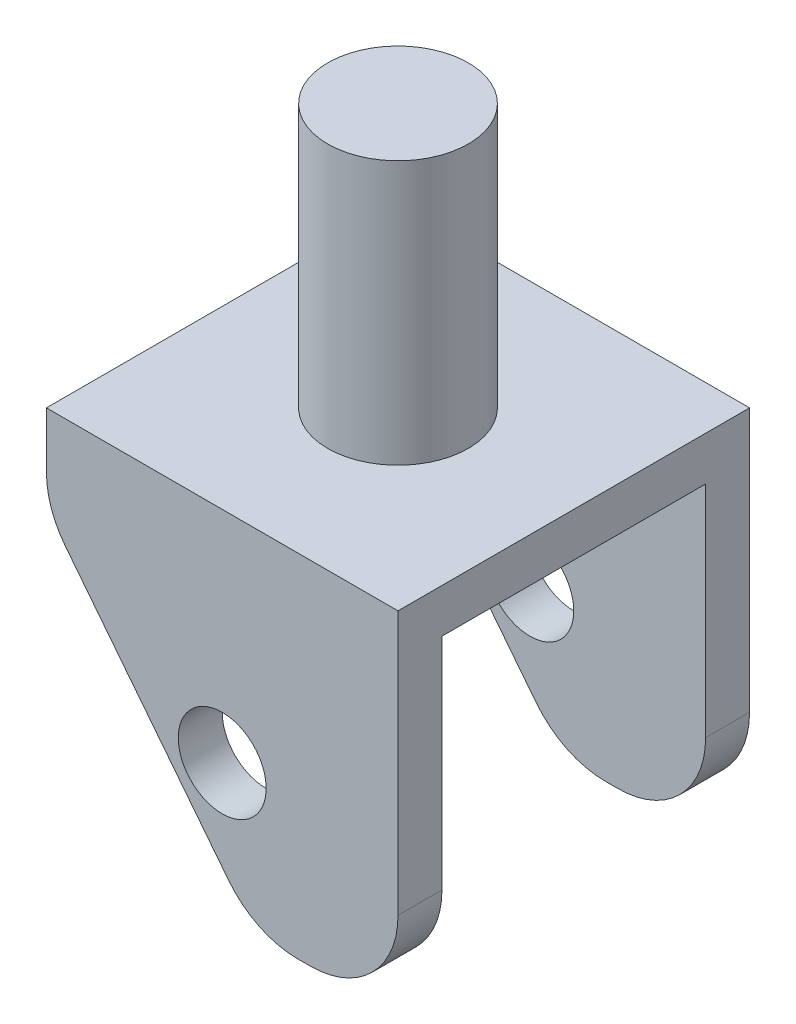
from build123d import *

# Parameters (mm, degrees)
DODANIE_WYCI_GNI_CIE1_DEPTH = 40
SZKIC2_W                    = 30
SZKIC2_H                    = 35
WYTNIJ_WYCI_GNI_CIE1_DEPTH  = 40
SZKIC3_R                    = 5
WYTNIJ_WYCI_GNI_CIE2_DEPTH  = 40
ZAOKR_GLENIE1_R             = 10
SZKIC4_R                    = 8
DODANIE_WYCI_GNI_CIE2_DEPTH = 30


with BuildPart() as part:
    # Szkic1 → Dodanie-wyciągnięcie1 (new body)
    with BuildSketch(Plane.XY):
        Polygon((-8.990228013, 22.917176047), (31.009771987, 22.917176047), (31.009771987, -17.082823953), (14.732595321, -17.082823953), (-8.990228013, 13.105888901), align=None)
    extrude(amount=DODANIE_WYCI_GNI_CIE1_DEPTH)

    # Szkic2 → Wytnij-wyciągnięcie1 (cut)
    with BuildSketch(Plane(origin=(31.009771987, 0, 0), x_dir=(0, 0, -1), z_dir=(1, 0, 0))):
        with Locations((-20, 0.417176047)):
            Rectangle(SZKIC2_W, SZKIC2_H)
    extrude(amount=-WYTNIJ_WYCI_GNI_CIE1_DEPTH, mode=Mode.SUBTRACT)

    # Szkic3 → Wytnij-wyciągnięcie2 (cut)
    with BuildSketch(Plane(origin=(0, 0, 0), x_dir=(-1, 0, 0), z_dir=(0, 0, -1))):
        with Locations((-11.009771987, -2.082823953)):
            Circle(SZKIC3_R)
    extrude(amount=-WYTNIJ_WYCI_GNI_CIE2_DEPTH, mode=Mode.SUBTRACT)

    # Zaokrąglenie1
    zaokr_glenie1_edges = [part.edges().sort_by_distance(p)[0] for p in [
        (31.009771987, -17.082823953, 2.5),
        (14.732595321, -17.082823953, 2.5),
        (-8.990228013, 13.105888901, 2.5),
        (31.009771987, -17.082823953, 37.5),
        (14.732595321, -17.082823953, 37.5),
        (-8.990228013, 13.105888901, 37.5),
    ]]
    fillet(zaokr_glenie1_edges, radius=ZAOKR_GLENIE1_R)

    # Szkic4 → Dodanie-wyciągnięcie2 (add)
    with BuildSketch(Plane(origin=(0, 22.917176047, 0), x_dir=(1, 0, 0), z_dir=(0, 1, 0))):
        with Locations((11.009771987, -20)):
            Circle(SZKIC4_R)
    extrude(amount=DODANIE_WYCI_GNI_CIE2_DEPTH)


solid = part.part
